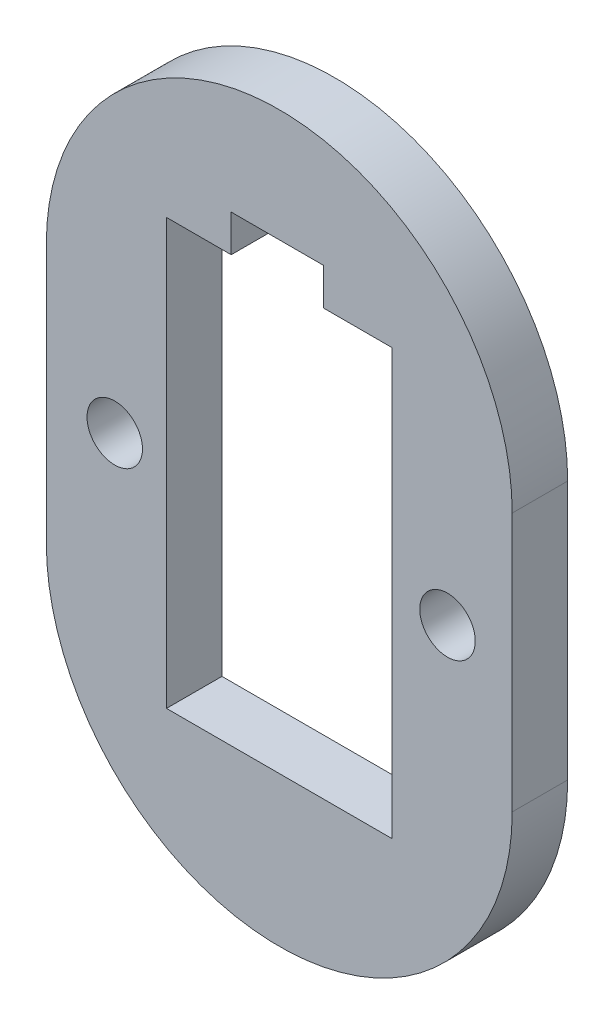
from build123d import *

# Parameters (mm, degrees)
MODEL_R             = 1.5
BOSS_EXTRUDE1_DEPTH = 3


with BuildPart() as part:
    # Model → Boss-Extrude1 (new body)
    with BuildSketch(Plane.XY):
        with BuildLine():
            Line((0.88624, 25.209039561), (0.88624, 11.208991882))
            ThreePointArc((0.88624, 11.208991882), (13.486238839, -1.391009279), (26.08624, 11.20898956))
            Line((26.08624, 11.20898956), (26.08624, 25.209041884))
            ThreePointArc((26.08624, 25.209041884), (13.486238839, 37.809039561), (0.88624, 25.209039561))
        make_face()
        with Locations((4.586289997, 18.209039557)):
            Circle(MODEL_R, mode=Mode.SUBTRACT)
        with Locations((22.586289997, 18.209039557)):
            Circle(MODEL_R, mode=Mode.SUBTRACT)
        Polygon((19.586238839, 6.708989561), (19.586238839, 29.708989561), (15.886238839, 29.708989561), (15.886238839, 31.708989561), (10.886238839, 31.708989561), (10.886238839, 29.708989561), (7.386238839, 29.708989561), (7.386238839, 6.708989561), align=None, mode=Mode.SUBTRACT)
    extrude(amount=BOSS_EXTRUDE1_DEPTH)


solid = part.part
